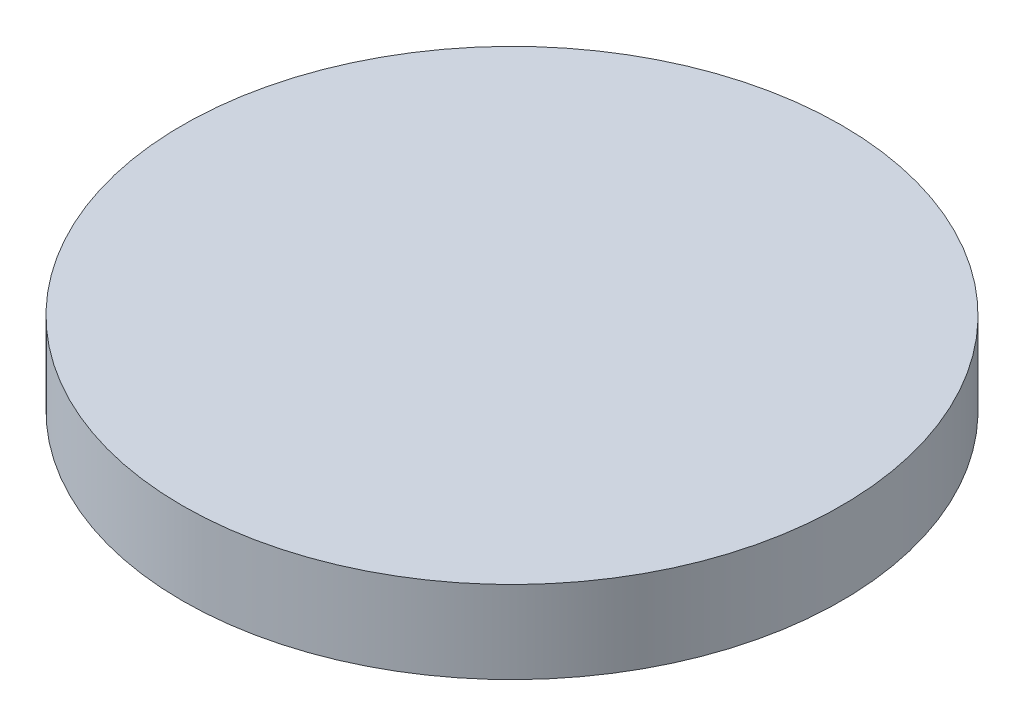
from build123d import *

# Parameters (mm, degrees)
SKETCH1_R           = 50.8
BOSS_EXTRUDE1_DEPTH = 12.7


with BuildPart() as part:
    # Sketch1 → Boss-Extrude1 (new body)
    with BuildSketch(Plane(origin=(0, 0, 0), x_dir=(1, 0, 0), z_dir=(0, 1, 0))):
        with Locations((-55.522966501, 32.261050872)):
            Circle(SKETCH1_R)
    extrude(amount=BOSS_EXTRUDE1_DEPTH)


solid = part.part
